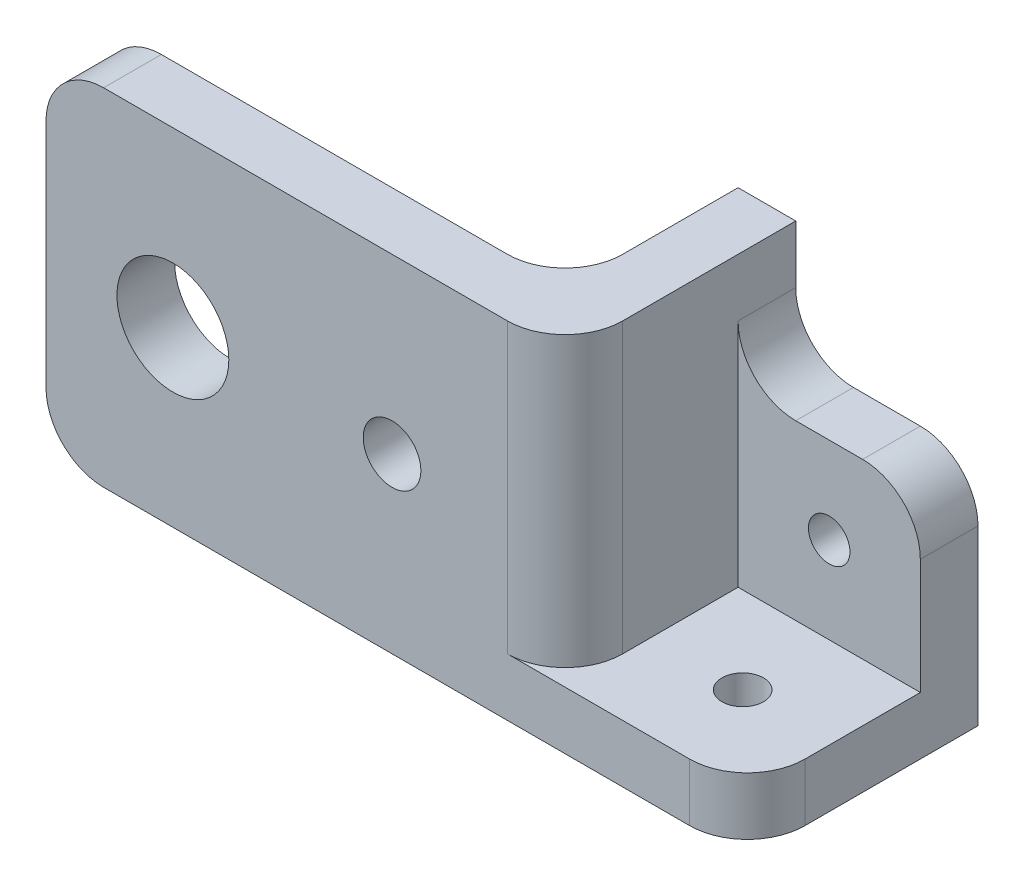
from build123d import *

# Parameters (mm, degrees)
SKETCH1_W           = 20.066
SKETCH1_H           = 25.4
BOSS_EXTRUDE1_DEPTH = 6.35
SKETCH2_W           = 20.066
SKETCH2_H           = 25.4
BOSS_EXTRUDE2_DEPTH = 6.35
SKETCH3_W           = 25.4
SKETCH3_H           = 38.1
BOSS_EXTRUDE3_DEPTH = 6.35
SKETCH4_W           = 50.8
SKETCH4_H           = 38.1
BOSS_EXTRUDE4_DEPTH = 6.35
SKETCH6_R           = 2.286
CUT_EXTRUDE1_DEPTH  = 7.35
SKETCH7_R           = 2.286
CUT_EXTRUDE2_DEPTH  = 7.35
SKETCH8_R           = 6.1595
SKETCH8_R_2         = 3.175
CUT_EXTRUDE3_DEPTH  = 26.4
FILLET1_R           = 6.35


with BuildPart() as part:
    # Sketch1 → Boss-Extrude1 (new body)
    with BuildSketch(Plane(origin=(0, 0, 0), x_dir=(1, 0, 0), z_dir=(0, 1, 0))):
        Rectangle(SKETCH1_W, SKETCH1_H)
    extrude(amount=BOSS_EXTRUDE1_DEPTH)

    # Sketch2 → Boss-Extrude2 (add)
    with BuildSketch(Plane(origin=(0, 0, -12.7), x_dir=(-1, 0, 0), z_dir=(0, 0, -1))):
        with Locations((0, 12.7)):
            Rectangle(SKETCH2_W, SKETCH2_H)
    extrude(amount=-BOSS_EXTRUDE2_DEPTH)

    # Sketch3 → Boss-Extrude3 (add)
    with BuildSketch(Plane.ZY.offset(10.033)):
        with Locations((0, 19.05)):
            Rectangle(SKETCH3_W, SKETCH3_H)
    extrude(amount=BOSS_EXTRUDE3_DEPTH)

    # Sketch4 → Boss-Extrude4 (add)
    with BuildSketch(Plane.XY.offset(12.7)):
        with Locations((-41.783, 19.05)):
            Rectangle(SKETCH4_W, SKETCH4_H)
    extrude(amount=-BOSS_EXTRUDE4_DEPTH)

    # Sketch6 → Cut-Extrude1 (cut, through all)
    with BuildSketch(Plane.XY.offset(-6.35)):
        with Locations((0, 15.875)):
            Circle(SKETCH6_R)
    extrude(amount=-CUT_EXTRUDE1_DEPTH, mode=Mode.SUBTRACT)

    # Sketch7 → Cut-Extrude2 (cut, through all)
    with BuildSketch(Plane(origin=(0, 6.35, 0), x_dir=(1, 0, 0), z_dir=(0, 1, 0))):
        with Locations((0, -3.175)):
            Circle(SKETCH7_R)
    extrude(amount=-CUT_EXTRUDE2_DEPTH, mode=Mode.SUBTRACT)

    # Sketch8 → Cut-Extrude3 (cut, through all)
    with BuildSketch(Plane.XY.offset(12.7)):
        with Locations((-53.213, 19.05)):
            Circle(SKETCH8_R)
        with Locations((-29.083, 19.05)):
            Circle(SKETCH8_R_2)
    extrude(amount=-CUT_EXTRUDE3_DEPTH, mode=Mode.SUBTRACT)

    # Fillet1
    fillet1_edges = [part.edges().sort_by_distance(p)[0] for p in [
        (-10.033, 25.4, -9.525),
        (10.033, 25.4, -9.525),
        (-10.033, 22.225, 12.7),
        (-16.383, 19.05, 6.35),
        (-67.183, 0, 9.525),
        (-67.183, 38.1, 9.525),
        (10.033, 3.175, 12.7),
    ]]
    fillet(fillet1_edges, radius=FILLET1_R)


solid = part.part
